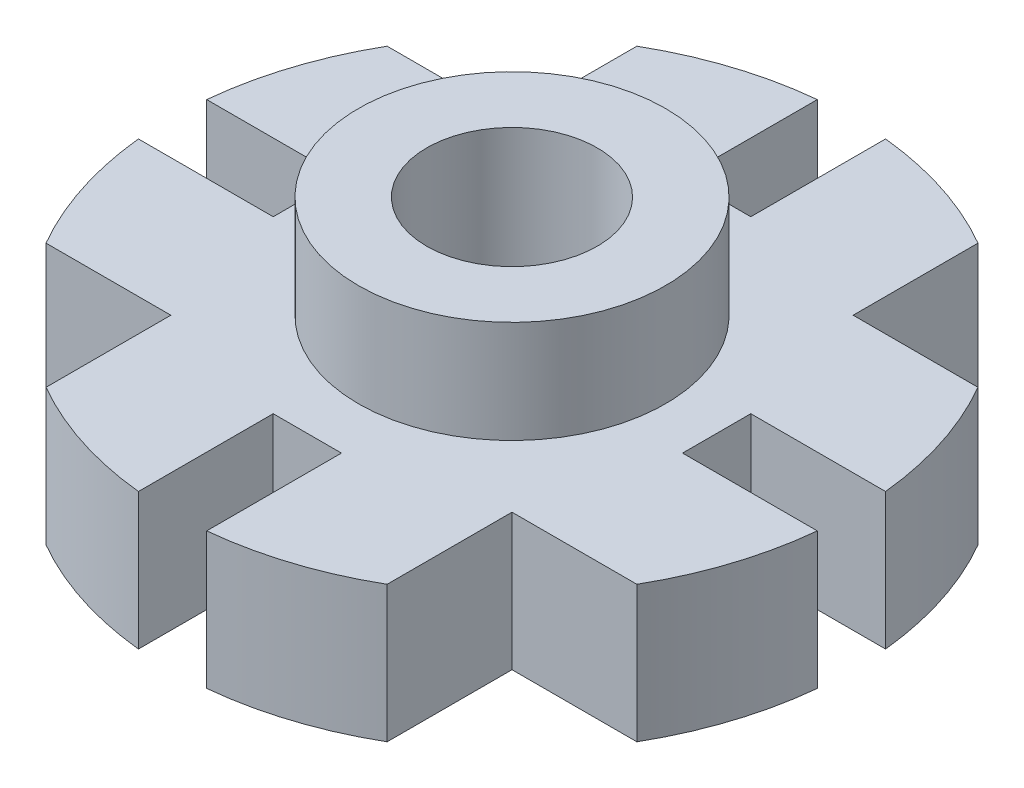
from build123d import *

# Parameters (mm, degrees)
SKETCH1_R           = 63.5
BOSS_EXTRUDE1_DEPTH = 25.4
SKETCH2_R           = 28.575
BOSS_EXTRUDE2_DEPTH = 19.05
SKETCH3_W           = 25.4
SKETCH3_H           = 12.7
SKETCH3_W_2         = 12.7
SKETCH3_H_2         = 25.4
CUT_EXTRUDE1_DEPTH  = 26.4
SKETCH4_W           = 25.4
SKETCH4_H           = 25.4
CUT_EXTRUDE2_DEPTH  = 26.4
SKETCH5_R           = 15.875
CUT_EXTRUDE3_DEPTH  = 45.45


with BuildPart() as part:
    # Sketch1 → Boss-Extrude1 (new body)
    with BuildSketch(Plane(origin=(0, 0, 0), x_dir=(1, 0, 0), z_dir=(0, 1, 0))):
        Circle(SKETCH1_R)
    extrude(amount=-BOSS_EXTRUDE1_DEPTH)

    # Sketch2 → Boss-Extrude2 (add)
    with BuildSketch(Plane(origin=(0, 0, 0), x_dir=(1, 0, 0), z_dir=(0, 1, 0))):
        Circle(SKETCH2_R)
    extrude(amount=BOSS_EXTRUDE2_DEPTH)

    # Sketch3 → Cut-Extrude1 (cut, through all)
    with BuildSketch(Plane(origin=(0, 0, 0), x_dir=(1, 0, 0), z_dir=(0, 1, 0))):
        with Locations((50.8, 0)):
            Rectangle(SKETCH3_W, SKETCH3_H)
        with Locations((0, 50.8)):
            Rectangle(SKETCH3_W_2, SKETCH3_H_2)
        with Locations((0, -50.8)):
            Rectangle(SKETCH3_W_2, SKETCH3_H_2)
        with Locations((-50.8, 0)):
            Rectangle(SKETCH3_W, SKETCH3_H)
    extrude(amount=-CUT_EXTRUDE1_DEPTH, mode=Mode.SUBTRACT)

    # Sketch4 → Cut-Extrude2 (cut, through all)
    with BuildSketch(Plane(origin=(0, 0, 0), x_dir=(1, 0, 0), z_dir=(0, 1, 0))):
        with Locations((-44.45, 44.45)):
            Rectangle(SKETCH4_W, SKETCH4_H)
        with Locations((44.45, 44.45)):
            Rectangle(SKETCH4_W, SKETCH4_H)
        with Locations((44.45, -44.45)):
            Rectangle(SKETCH4_W, SKETCH4_H)
        with Locations((-44.45, -44.45)):
            Rectangle(SKETCH4_W, SKETCH4_H)
    extrude(amount=-CUT_EXTRUDE2_DEPTH, mode=Mode.SUBTRACT)

    # Sketch5 → Cut-Extrude3 (cut, through all)
    with BuildSketch(Plane(origin=(0, 19.05, 0), x_dir=(1, 0, 0), z_dir=(0, 1, 0))):
        Circle(SKETCH5_R)
    extrude(amount=-CUT_EXTRUDE3_DEPTH, mode=Mode.SUBTRACT)


solid = part.part
